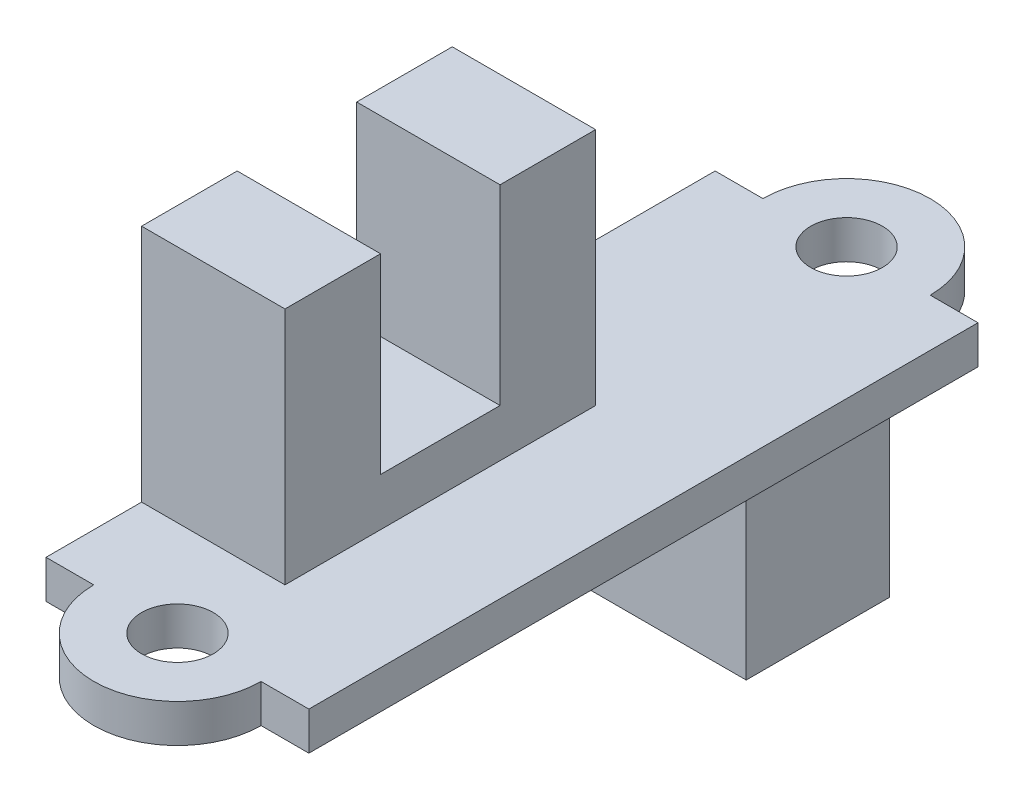
from build123d import *

# Parameters (mm, degrees)
SKETCH1_R           = 1.5
BOSS_EXTRUDE1_DEPTH = 1.6
BOSS_EXTRUDE2_START = -11
BOSS_EXTRUDE2_DEPTH = 6
SKETCH5_W           = 10
SKETCH5_H           = 6
BOSS_EXTRUDE3_DEPTH = 7


with BuildPart() as part:
    # Sketch1 → Boss-Extrude1 (new body)
    with BuildSketch(Plane(origin=(0, 0, 0), x_dir=(1, 0, 0), z_dir=(0, 1, 0))):
        with BuildLine():
            Line((-5.5, 28), (-3.5, 28))
            ThreePointArc((-3.5, 28), (0, 31.5), (3.5, 28))
            Line((3.5, 28), (5.5, 28))
            Line((5.5, 28), (5.5, 0))
            Line((5.5, 0), (3.5, 0))
            ThreePointArc((3.5, 0), (0, -3.5), (-3.5, 0))
            Line((-3.5, 0), (-5.5, 0))
            Line((-5.5, 0), (-5.5, 28))
        make_face()
        Circle(SKETCH1_R, mode=Mode.SUBTRACT)
        with Locations((0, 28)):
            Circle(SKETCH1_R, mode=Mode.SUBTRACT)
    extrude(amount=BOSS_EXTRUDE1_DEPTH)

    # Sketch3 → Boss-Extrude2 (add)
    with BuildSketch(Plane(origin=(5.5, 0, 0), x_dir=(0, 0, -1), z_dir=(1, 0, 0)).offset(BOSS_EXTRUDE2_START)):
        Polygon((4, 1.6), (4, 11.6), (8, 11.6), (8, 3.6), (13, 3.6), (13, 11.6), (17, 11.6), (17, 1.6), align=None)
    extrude(amount=BOSS_EXTRUDE2_DEPTH)

    # Sketch5 → Boss-Extrude3 (add)
    with BuildSketch(Plane.XZ):
        with Locations((0, -21.8)):
            Rectangle(SKETCH5_W, SKETCH5_H)
    extrude(amount=BOSS_EXTRUDE3_DEPTH)


solid = part.part
